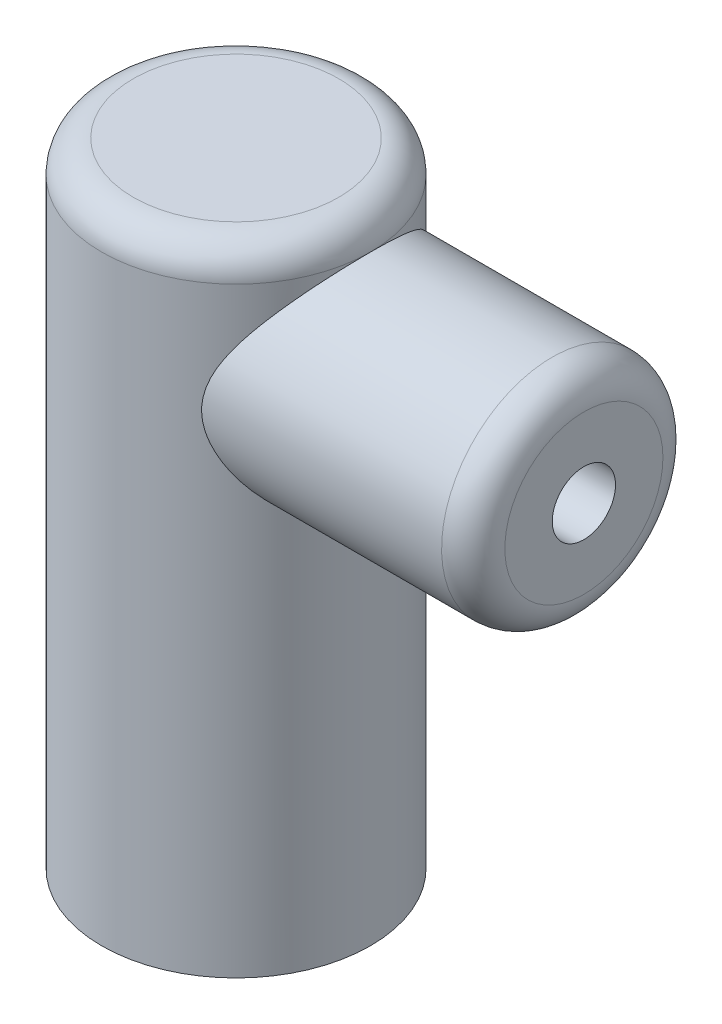
from build123d import *

# Parameters (mm, degrees)
SKETCH1_R           = 42.5
BOSS_EXTRUDE1_DEPTH = 200
SKETCH2_R           = 35
BOSS_EXTRUDE2_DEPTH = 110
FILLET1_R           = 10
SKETCH3_R           = 10
CUT_EXTRUDE1_DEPTH  = 40
FILLET2_R           = 10


with BuildPart() as part:
    # Sketch1 → Boss-Extrude1 (new body)
    with BuildSketch(Plane(origin=(0, 0, 0), x_dir=(1, 0, 0), z_dir=(0, 1, 0))):
        Circle(SKETCH1_R)
    extrude(amount=BOSS_EXTRUDE1_DEPTH)

    # Sketch2 → Boss-Extrude2 (add)
    with BuildSketch(Plane(origin=(0, 0, 0), x_dir=(0, 0, -1), z_dir=(1, 0, 0))):
        with Locations((0, 155)):
            Circle(SKETCH2_R)
    extrude(amount=BOSS_EXTRUDE2_DEPTH)

    # Fillet1
    fillet1_edges = [part.edges().sort_by_distance(p)[0] for p in [
        (-42.5, 200, 0),
    ]]
    fillet(fillet1_edges, radius=FILLET1_R)

    # Sketch3 → Cut-Extrude1 (cut)
    with BuildSketch(Plane(origin=(110, 0, 0), x_dir=(0, 0, -1), z_dir=(1, 0, 0))):
        with Locations((0, 155)):
            Circle(SKETCH3_R)
    extrude(amount=-CUT_EXTRUDE1_DEPTH, mode=Mode.SUBTRACT)

    # Fillet2
    fillet2_edges = [part.edges().sort_by_distance(p)[0] for p in [
        (110, 155, 35),
    ]]
    fillet(fillet2_edges, radius=FILLET2_R)


solid = part.part
